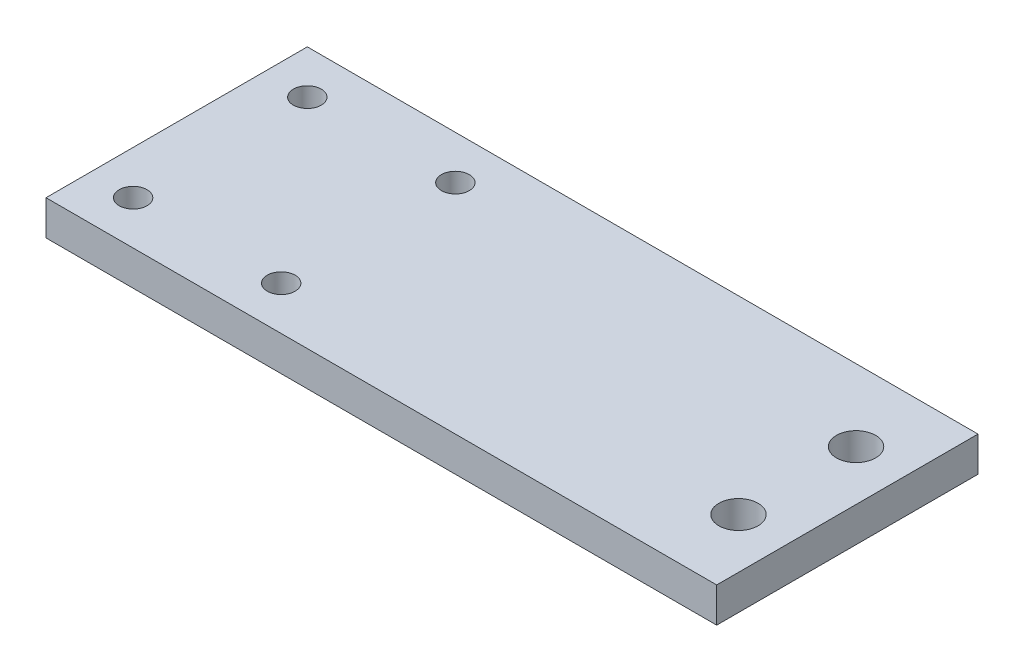
from build123d import *

# Parameters (mm, degrees)
SKETCH_1_W      = 77
SKETCH_1_H      = 30
SKETCH_1_R      = 1.6
SKETCH_1_R_2    = 2.25
EXTRUDE_1_DEPTH = 4


with BuildPart() as part:
    # 草图1 → 凸台-拉伸1 (new body)
    with BuildSketch(Plane(origin=(0, 0, 0), x_dir=(1, 0, 0), z_dir=(0, 1, 0))):
        with Locations((-3.5, 10)):
            Rectangle(SKETCH_1_W, SKETCH_1_H)
        with Locations((-20, 20)):
            Circle(SKETCH_1_R, mode=Mode.SUBTRACT)
        with Locations((-37, 20)):
            Circle(SKETCH_1_R, mode=Mode.SUBTRACT)
        with Locations((-20, 0)):
            Circle(SKETCH_1_R, mode=Mode.SUBTRACT)
        with Locations((-37, 0)):
            Circle(SKETCH_1_R, mode=Mode.SUBTRACT)
        with Locations((29.25, 16.75)):
            Circle(SKETCH_1_R_2, mode=Mode.SUBTRACT)
        with Locations((29.25, 3.25)):
            Circle(SKETCH_1_R_2, mode=Mode.SUBTRACT)
    extrude(amount=EXTRUDE_1_DEPTH)


solid = part.part
